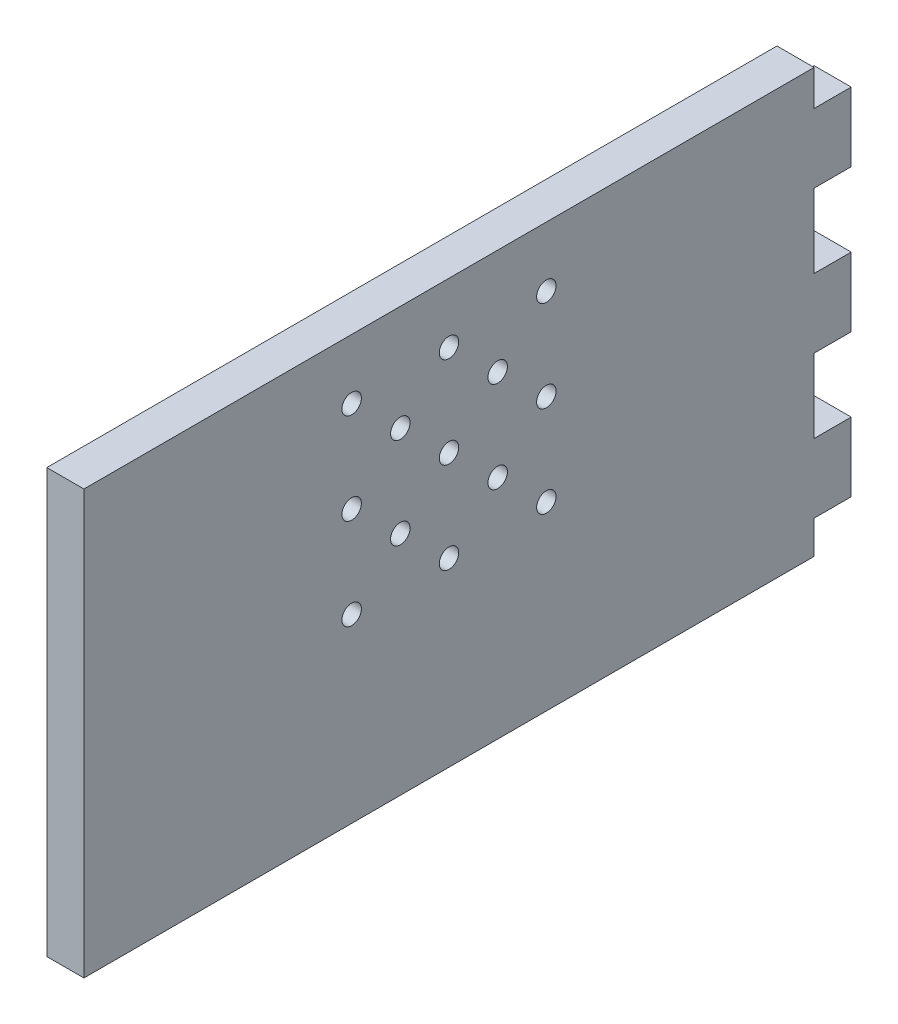
from build123d import *

# Parameters (mm, degrees)
ESQUISSE1_W             = 15.25
ESQUISSE1_H             = 174
BOSS_EXTRU_1_DEPTH      = 300
ESQUISSE2_W             = 15.25
ESQUISSE2_H             = 28.357142857
BOSS_EXTRU_2_DEPTH      = 15.25
ENL_V_MAT_EXTRU_1_REACH = 17.25
ESQUISSE3_R             = 4


with BuildPart() as part:
    # Esquisse1 → Boss.-Extru.1 (new body)
    with BuildSketch(Plane.XY):
        with Locations((457.625, 83.063864629)):
            Rectangle(ESQUISSE1_W, ESQUISSE1_H)
    extrude(amount=BOSS_EXTRU_1_DEPTH)

    # Esquisse2 → Boss.-Extru.2 (add)
    with BuildSketch(Plane(origin=(465.25, 0, 0), x_dir=(0, 0, -1), z_dir=(1, 0, 0))):
        with Locations((7.625, 141.278150344)):
            Rectangle(ESQUISSE2_W, ESQUISSE2_H)
        with Locations((7.625, 82.563864628)):
            Rectangle(ESQUISSE2_W, ESQUISSE2_H)
        with Locations((7.625, 23.849578915)):
            Rectangle(ESQUISSE2_W, ESQUISSE2_H)
    extrude(amount=-BOSS_EXTRU_2_DEPTH)

    # Esquisse3 → Enlèv. mat.-Extru.1 (cut, up to next)
    with BuildSketch(Plane(origin=(465.25, 0, 0), x_dir=(0, 0, -1), z_dir=(1, 0, 0)), mode=Mode.PRIVATE) as enl_v_mat_extru_1_sk1:
        with Locations((-110, 145.456721772)):
            Circle(ESQUISSE3_R)
    enl_v_mat_extru_1_tool1 = extrude(enl_v_mat_extru_1_sk1.sketch, amount=-ENL_V_MAT_EXTRU_1_REACH, mode=Mode.PRIVATE) & part.part
    add(enl_v_mat_extru_1_tool1.solids().sort_by_distance((465.25, 145.456722, 110))[0], mode=Mode.SUBTRACT)
    # Esquisse3 → Enlèv. mat.-Extru.1 (cut, up to next)
    with BuildSketch(Plane(origin=(465.25, 0, 0), x_dir=(0, 0, -1), z_dir=(1, 0, 0)), mode=Mode.PRIVATE) as enl_v_mat_extru_1_sk2:
        with Locations((-110, 70.456721772)):
            Circle(ESQUISSE3_R)
    enl_v_mat_extru_1_tool2 = extrude(enl_v_mat_extru_1_sk2.sketch, amount=-ENL_V_MAT_EXTRU_1_REACH, mode=Mode.PRIVATE) & part.part
    add(enl_v_mat_extru_1_tool2.solids().sort_by_distance((465.25, 70.456722, 110))[0], mode=Mode.SUBTRACT)
    # Esquisse3 → Enlèv. mat.-Extru.1 (cut, up to next)
    with BuildSketch(Plane(origin=(465.25, 0, 0), x_dir=(0, 0, -1), z_dir=(1, 0, 0)), mode=Mode.PRIVATE) as enl_v_mat_extru_1_sk3:
        with Locations((-150, 70.456721772)):
            Circle(ESQUISSE3_R)
    enl_v_mat_extru_1_tool3 = extrude(enl_v_mat_extru_1_sk3.sketch, amount=-ENL_V_MAT_EXTRU_1_REACH, mode=Mode.PRIVATE) & part.part
    add(enl_v_mat_extru_1_tool3.solids().sort_by_distance((465.25, 70.456722, 150))[0], mode=Mode.SUBTRACT)
    # Esquisse3 → Enlèv. mat.-Extru.1 (cut, up to next)
    with BuildSketch(Plane(origin=(465.25, 0, 0), x_dir=(0, 0, -1), z_dir=(1, 0, 0)), mode=Mode.PRIVATE) as enl_v_mat_extru_1_sk4:
        with Locations((-150, 145.456721772)):
            Circle(ESQUISSE3_R)
    enl_v_mat_extru_1_tool4 = extrude(enl_v_mat_extru_1_sk4.sketch, amount=-ENL_V_MAT_EXTRU_1_REACH, mode=Mode.PRIVATE) & part.part
    add(enl_v_mat_extru_1_tool4.solids().sort_by_distance((465.25, 145.456722, 150))[0], mode=Mode.SUBTRACT)
    # Esquisse3 → Enlèv. mat.-Extru.1 (cut, up to next)
    with BuildSketch(Plane(origin=(465.25, 0, 0), x_dir=(0, 0, -1), z_dir=(1, 0, 0)), mode=Mode.PRIVATE) as enl_v_mat_extru_1_sk5:
        with Locations((-190, 145.456721772)):
            Circle(ESQUISSE3_R)
    enl_v_mat_extru_1_tool5 = extrude(enl_v_mat_extru_1_sk5.sketch, amount=-ENL_V_MAT_EXTRU_1_REACH, mode=Mode.PRIVATE) & part.part
    add(enl_v_mat_extru_1_tool5.solids().sort_by_distance((465.25, 145.456722, 190))[0], mode=Mode.SUBTRACT)
    # Esquisse3 → Enlèv. mat.-Extru.1 (cut, up to next)
    with BuildSketch(Plane(origin=(465.25, 0, 0), x_dir=(0, 0, -1), z_dir=(1, 0, 0)), mode=Mode.PRIVATE) as enl_v_mat_extru_1_sk6:
        with Locations((-190, 70.456721772)):
            Circle(ESQUISSE3_R)
    enl_v_mat_extru_1_tool6 = extrude(enl_v_mat_extru_1_sk6.sketch, amount=-ENL_V_MAT_EXTRU_1_REACH, mode=Mode.PRIVATE) & part.part
    add(enl_v_mat_extru_1_tool6.solids().sort_by_distance((465.25, 70.456722, 190))[0], mode=Mode.SUBTRACT)
    # Esquisse3 → Enlèv. mat.-Extru.1 (cut, up to next)
    with BuildSketch(Plane(origin=(465.25, 0, 0), x_dir=(0, 0, -1), z_dir=(1, 0, 0)), mode=Mode.PRIVATE) as enl_v_mat_extru_1_sk7:
        with Locations((-130, 126.706721772)):
            Circle(ESQUISSE3_R)
    enl_v_mat_extru_1_tool7 = extrude(enl_v_mat_extru_1_sk7.sketch, amount=-ENL_V_MAT_EXTRU_1_REACH, mode=Mode.PRIVATE) & part.part
    add(enl_v_mat_extru_1_tool7.solids().sort_by_distance((465.25, 126.706722, 130))[0], mode=Mode.SUBTRACT)
    # Esquisse3 → Enlèv. mat.-Extru.1 (cut, up to next)
    with BuildSketch(Plane(origin=(465.25, 0, 0), x_dir=(0, 0, -1), z_dir=(1, 0, 0)), mode=Mode.PRIVATE) as enl_v_mat_extru_1_sk8:
        with Locations((-170, 126.706721772)):
            Circle(ESQUISSE3_R)
    enl_v_mat_extru_1_tool8 = extrude(enl_v_mat_extru_1_sk8.sketch, amount=-ENL_V_MAT_EXTRU_1_REACH, mode=Mode.PRIVATE) & part.part
    add(enl_v_mat_extru_1_tool8.solids().sort_by_distance((465.25, 126.706722, 170))[0], mode=Mode.SUBTRACT)
    # Esquisse3 → Enlèv. mat.-Extru.1 (cut, up to next)
    with BuildSketch(Plane(origin=(465.25, 0, 0), x_dir=(0, 0, -1), z_dir=(1, 0, 0)), mode=Mode.PRIVATE) as enl_v_mat_extru_1_sk9:
        with Locations((-190, 107.956721772)):
            Circle(ESQUISSE3_R)
    enl_v_mat_extru_1_tool9 = extrude(enl_v_mat_extru_1_sk9.sketch, amount=-ENL_V_MAT_EXTRU_1_REACH, mode=Mode.PRIVATE) & part.part
    add(enl_v_mat_extru_1_tool9.solids().sort_by_distance((465.25, 107.956722, 190))[0], mode=Mode.SUBTRACT)
    # Esquisse3 → Enlèv. mat.-Extru.1 (cut, up to next)
    with BuildSketch(Plane(origin=(465.25, 0, 0), x_dir=(0, 0, -1), z_dir=(1, 0, 0)), mode=Mode.PRIVATE) as enl_v_mat_extru_1_sk10:
        with Locations((-170, 89.206721772)):
            Circle(ESQUISSE3_R)
    enl_v_mat_extru_1_tool10 = extrude(enl_v_mat_extru_1_sk10.sketch, amount=-ENL_V_MAT_EXTRU_1_REACH, mode=Mode.PRIVATE) & part.part
    add(enl_v_mat_extru_1_tool10.solids().sort_by_distance((465.25, 89.206722, 170))[0], mode=Mode.SUBTRACT)
    # Esquisse3 → Enlèv. mat.-Extru.1 (cut, up to next)
    with BuildSketch(Plane(origin=(465.25, 0, 0), x_dir=(0, 0, -1), z_dir=(1, 0, 0)), mode=Mode.PRIVATE) as enl_v_mat_extru_1_sk11:
        with Locations((-130, 89.206721772)):
            Circle(ESQUISSE3_R)
    enl_v_mat_extru_1_tool11 = extrude(enl_v_mat_extru_1_sk11.sketch, amount=-ENL_V_MAT_EXTRU_1_REACH, mode=Mode.PRIVATE) & part.part
    add(enl_v_mat_extru_1_tool11.solids().sort_by_distance((465.25, 89.206722, 130))[0], mode=Mode.SUBTRACT)
    # Esquisse3 → Enlèv. mat.-Extru.1 (cut, up to next)
    with BuildSketch(Plane(origin=(465.25, 0, 0), x_dir=(0, 0, -1), z_dir=(1, 0, 0)), mode=Mode.PRIVATE) as enl_v_mat_extru_1_sk12:
        with Locations((-110, 107.956721772)):
            Circle(ESQUISSE3_R)
    enl_v_mat_extru_1_tool12 = extrude(enl_v_mat_extru_1_sk12.sketch, amount=-ENL_V_MAT_EXTRU_1_REACH, mode=Mode.PRIVATE) & part.part
    add(enl_v_mat_extru_1_tool12.solids().sort_by_distance((465.25, 107.956722, 110))[0], mode=Mode.SUBTRACT)
    # Esquisse3 → Enlèv. mat.-Extru.1 (cut, up to next)
    with BuildSketch(Plane(origin=(465.25, 0, 0), x_dir=(0, 0, -1), z_dir=(1, 0, 0)), mode=Mode.PRIVATE) as enl_v_mat_extru_1_sk13:
        with Locations((-150, 107.956721772)):
            Circle(ESQUISSE3_R)
    enl_v_mat_extru_1_tool13 = extrude(enl_v_mat_extru_1_sk13.sketch, amount=-ENL_V_MAT_EXTRU_1_REACH, mode=Mode.PRIVATE) & part.part
    add(enl_v_mat_extru_1_tool13.solids().sort_by_distance((465.25, 107.956722, 150))[0], mode=Mode.SUBTRACT)


solid = part.part
